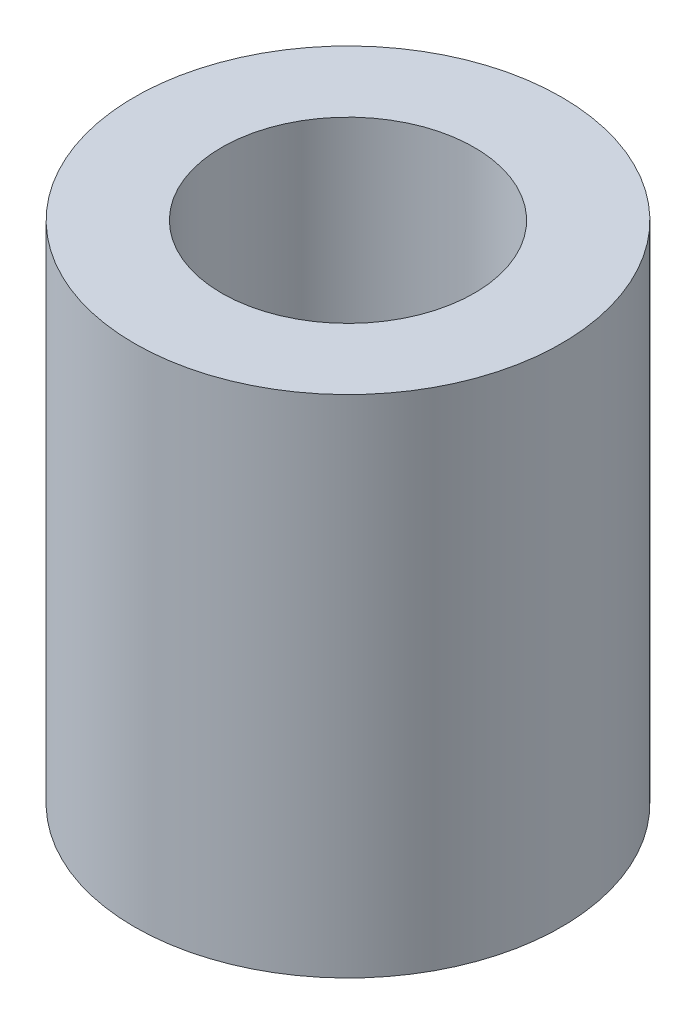
from build123d import *

# Parameters (mm, degrees)
SKETCH1_R           = 10.7315
SKETCH1_R_2         = 6.35
BOSS_EXTRUDE1_DEPTH = 12.7


with BuildPart() as part:
    # Sketch1 → Boss-Extrude1 (new body, symmetric)
    with BuildSketch(Plane(origin=(0, 0, 0), x_dir=(1, 0, 0), z_dir=(0, 1, 0))):
        Circle(SKETCH1_R)
        Circle(SKETCH1_R_2, mode=Mode.SUBTRACT)
    extrude(amount=BOSS_EXTRUDE1_DEPTH, both=True)


solid = part.part
